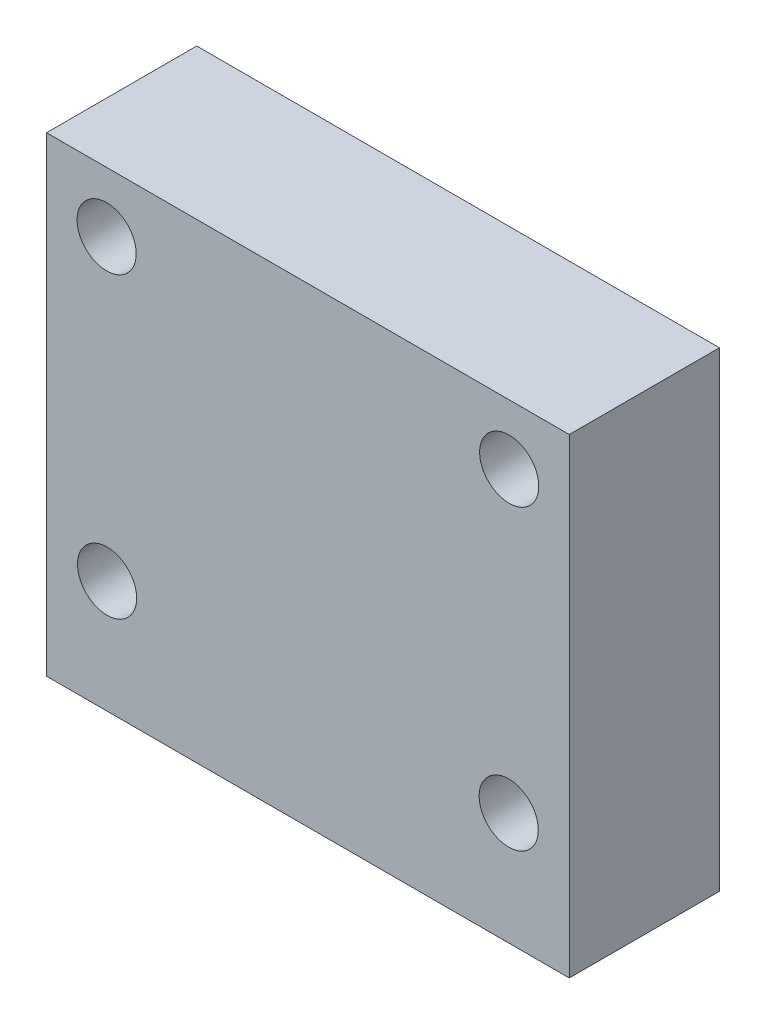
from build123d import *

# Parameters (mm, degrees)
SKETCH1_W          = 22.1
SKETCH1_H          = 19.9
EXTRUDE1_DEPTH     = 3.175
SKETCH2_R          = 1.03251
EXTRUDE2_DEPTH     = 12.7
SKETCH4_R          = 1.25
CUT_EXTRUDE1_DEPTH = 7.35


with BuildPart() as part:
    # Sketch1 → Extrude1 (new body, symmetric)
    with BuildSketch(Plane.XY):
        Rectangle(SKETCH1_W, SKETCH1_H)
    extrude(amount=EXTRUDE1_DEPTH, both=True)

    # Sketch2 → Extrude2 (cut)
    with BuildSketch(Plane.XZ.offset(9.95)):
        with Locations(Location((0, 0, 0), (0, 0, 270))):  # turned: the seam where the file's is
            Circle(SKETCH2_R)
    extrude(amount=-EXTRUDE2_DEPTH, mode=Mode.SUBTRACT)

    # Sketch4 → Cut-Extrude1 (cut, through all)
    with BuildSketch(Plane.XY.offset(3.175)):
        with Locations((8.49, -5.19)):
            Circle(SKETCH4_R)
        with Locations((-8.51, 7.41)):
            Circle(SKETCH4_R)
        with Locations((8.51, 7.41)):
            Circle(SKETCH4_R)
        with Locations((-8.49, -5.19)):
            Circle(SKETCH4_R)
    extrude(amount=-CUT_EXTRUDE1_DEPTH, mode=Mode.SUBTRACT)


solid = part.part
